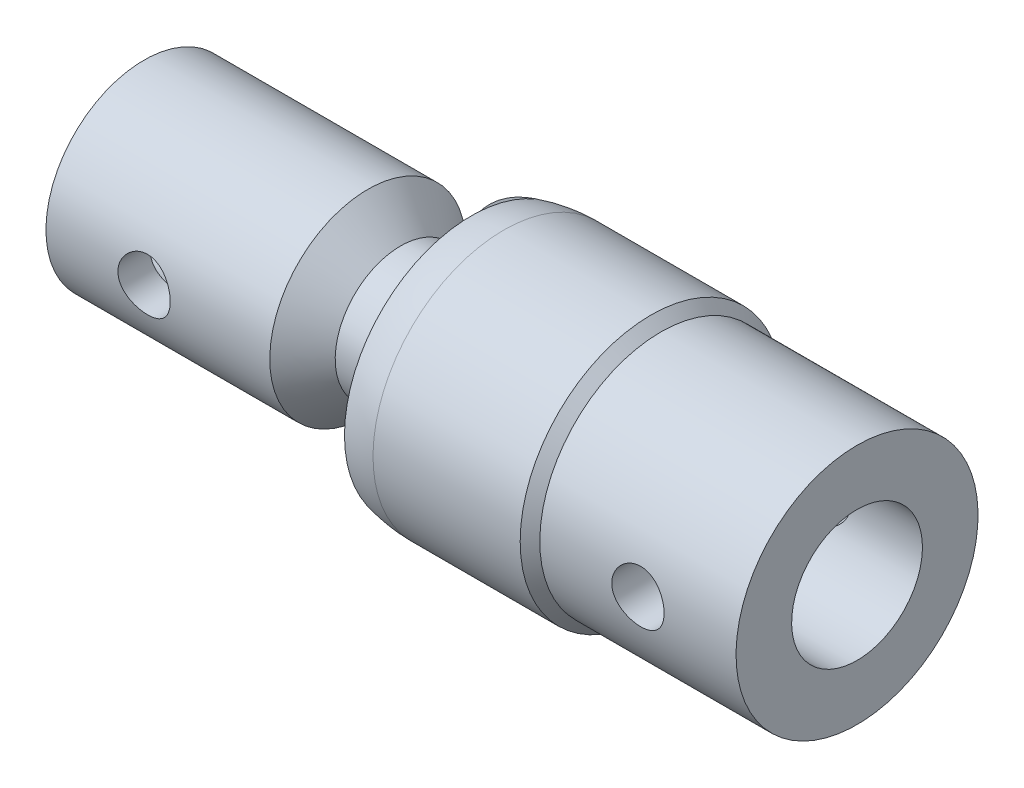
from build123d import *

# Parameters (mm, degrees)
CUT_EXTRUDE1_DEPTH      = 50.091855766
CUT_EXTRUDE1_DEPTH_BACK = 7.9375
SKETCH3_W               = 15.87627
SKETCH3_H               = 31.75
SKETCH5_W               = 7.93877
SKETCH5_H               = 13.748153286
CUT_EXTRUDE2_DEPTH      = 50.091855766
CUT_EXTRUDE3_DEPTH      = 50.091855766
CUT_EXTRUDE3_DEPTH_BACK = 50.091855766
SKETCH8_R               = 3.175


with BuildPart() as part:
    # Sketch1 → Revolve1 (revolve)
    with BuildSketch(Plane.XY):
        with BuildLine():
            Line((-12.528779942, -7.9375), (-8.874394786, -7.9375))
            ThreePointArc((-8.874394786, -7.9375), (4.248413006, -11.122489649), (11.90625, 0))
            Line((11.90625, 0), (-19.84502, 0))
            Line((-19.84502, 0), (-19.84502, -7.9375))
            Line((-19.84502, -7.9375), (-43.65752, -7.9375))
            Line((-43.65752, -7.9375), (-43.65752, -11.90625))
            Line((-43.65752, -11.90625), (-16.497529942, -11.90625))
            Line((-16.497529942, -11.90625), (-12.528779942, -7.9375))
        make_face()
    revolve(axis=Axis((-19.84502, 0, 0), (1, 0, 0)))


with BuildPart() as body_2:
    # Sketch2 → Revolve2 (revolve)
    with BuildSketch(Plane.XY):
        with BuildLine():
            Line((19.05, 0), (19.05, -7.9375))
            Line((19.05, -7.9375), (42.8625, -7.9375))
            Line((42.8625, -7.9375), (42.8625, -14.684375))
            Line((42.8625, -14.684375), (19.05, -14.684375))
            Line((19.05, -14.684375), (17.859375, -15.875))
            Line((17.859375, -15.875), (0, -15.875))
            ThreePointArc((0, -15.875), (-11.225320151, -11.225320151), (-15.875, 0))
            Line((-15.875, 0), (19.05, 0))
        make_face()
    revolve(axis=Axis((19.05, 0, 0), (-1, 0, 0)))

    # Sketch3 → Cut-Extrude1 (cut, two sides: drawn at the far end of the back side and taken through both)
    with BuildSketch(Plane.XY.offset(-CUT_EXTRUDE1_DEPTH_BACK)):
        with Locations((-11.906885, 0)):
            Rectangle(SKETCH3_W, SKETCH3_H)
    extrude(amount=CUT_EXTRUDE1_DEPTH + CUT_EXTRUDE1_DEPTH_BACK, mode=Mode.SUBTRACT)

    # Sketch5 → Cut-Extrude2 (cut, through all)
    with BuildSketch(Plane.XY):
        with Locations((-15.875635, 0)):
            Rectangle(SKETCH5_W, SKETCH5_H)
    extrude(amount=-CUT_EXTRUDE2_DEPTH, mode=Mode.SUBTRACT)

    # Sketch6 → Cut-Revolve2 (revolve, cut)
    with BuildSketch(Plane.XY):
        with BuildLine():
            Line((-12.16025, 0), (12.16025, 0))
            ThreePointArc((12.16025, 0), (0, -12.16025), (-12.16025, 0))
        make_face()
    revolve(axis=Axis((-12.16025, 0, 0), (1, 0, 0)), mode=Mode.SUBTRACT)


with BuildPart() as cut_extrude3_tool:
    # Sketch8 → Cut-Extrude3 (new, two sides: drawn at the far end of the back side and taken through both)
    with BuildSketch(Plane.XY.offset(-CUT_EXTRUDE3_DEPTH_BACK)):
        with Locations((-31.75127, 0)):
            Circle(SKETCH8_R)
        with Locations((30.95625, 0)):
            Circle(SKETCH8_R)
    extrude(amount=CUT_EXTRUDE3_DEPTH + CUT_EXTRUDE3_DEPTH_BACK)


with BuildPart() as part_1:
    add(part.part)

    # Cut-Extrude3: cut by cut_extrude3_tool
    add(cut_extrude3_tool.part, mode=Mode.SUBTRACT)


with BuildPart() as body_2_1:
    add(body_2.part)

    # Cut-Extrude3: cut by cut_extrude3_tool
    add(cut_extrude3_tool.part, mode=Mode.SUBTRACT)


solid = Compound([part_1.part, body_2_1.part])
